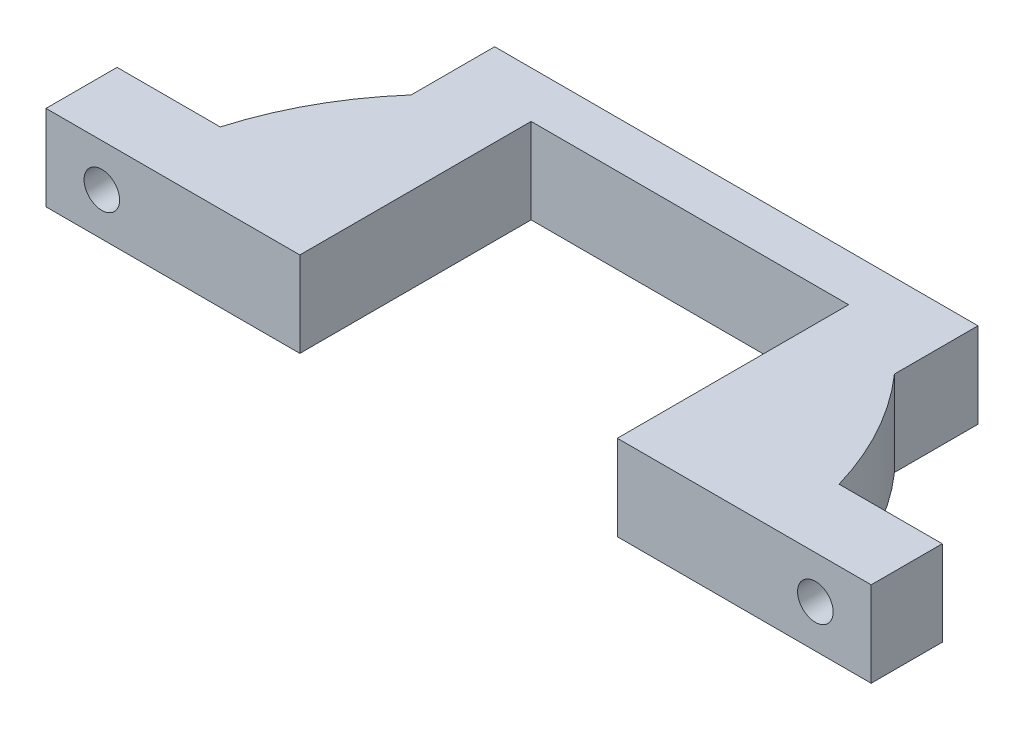
from build123d import *

# Parameters (mm, degrees)
SALIENTE_EXTRUIR1_DEPTH = 9
CROQUIS2_R              = 1.875
CORTAR_EXTRUIR1_DEPTH   = 50.514508735
CROQUIS2_3_R            = 3.5
CROQUIS2_3_R_2          = 1.875
CORTAR_EXTRUIR2_DEPTH   = 2.8


with BuildPart() as part:
    # Croquis1 → Saliente-Extruir1 (new body)
    with BuildSketch(Plane(origin=(0, 0, 0), x_dir=(1, 0, 0), z_dir=(0, 1, 0))):
        with BuildLine():
            Line((16.75, 2), (25.53429067, 2))
            Line((25.53429067, 2), (43.53429067, 2))
            Line((43.53429067, 2), (43.53429067, 9.5))
            Line((43.53429067, 9.5), (32.645826686, 9.5))
            ThreePointArc((32.645826686, 9.5), (29.789462584, 16.388652139), (25.5, 22.488886144))
            Line((25.5, 22.488886144), (25.5, 31.304864393))
            Line((25.5, 31.304864393), (-25.5, 31.304864393))
            Line((-25.5, 31.304864393), (-25.5, 22.488886144))
            ThreePointArc((-25.5, 22.488886144), (-29.789462584, 16.388652139), (-32.645826686, 9.5))
            Line((-32.645826686, 9.5), (-43.53429067, 9.5))
            Line((-43.53429067, 9.5), (-43.53429067, 2))
            Line((-43.53429067, 2), (-25.53429067, 2))
            Line((-25.53429067, 2), (-16.75, 2))
            Line((-16.75, 2), (-16.75, 26.402432196))
            Line((-16.75, 26.402432196), (16.75, 26.402432196))
            Line((16.75, 26.402432196), (16.75, 2))
        make_face()
    extrude(amount=SALIENTE_EXTRUIR1_DEPTH)

    # Croquis2 → Cortar-Extruir1 (cut, through all)
    with BuildSketch(Plane(origin=(0, 0, -9.5), x_dir=(-1, 0, 0), z_dir=(0, 0, -1))):
        with Locations((-37.645, 4.5)):
            Circle(CROQUIS2_R)
        with Locations((37.645, 4.5)):
            Circle(CROQUIS2_R)
    extrude(amount=-CORTAR_EXTRUIR1_DEPTH, mode=Mode.SUBTRACT)

    # Croquis2_3 → Cortar-Extruir2 (cut)
    # profile 1 of 2: a face of its own
    with BuildSketch(Plane(origin=(0, 0, -9.5), x_dir=(-1, 0, 0), z_dir=(0, 0, -1))):
        with Locations((-37.645, 4.5)):
            Circle(CROQUIS2_3_R)
        with Locations((-37.645, 4.5)):
            Circle(CROQUIS2_3_R_2, mode=Mode.SUBTRACT)
    # profile 2 of 2: a face of its own
    with BuildSketch(Plane(origin=(0, 0, -9.5), x_dir=(-1, 0, 0), z_dir=(0, 0, -1))):
        with Locations((37.645, 4.5)):
            Circle(CROQUIS2_3_R)
        with Locations((37.645, 4.5)):
            Circle(CROQUIS2_3_R_2, mode=Mode.SUBTRACT)
    extrude(amount=-CORTAR_EXTRUIR2_DEPTH, mode=Mode.SUBTRACT)


solid = part.part
